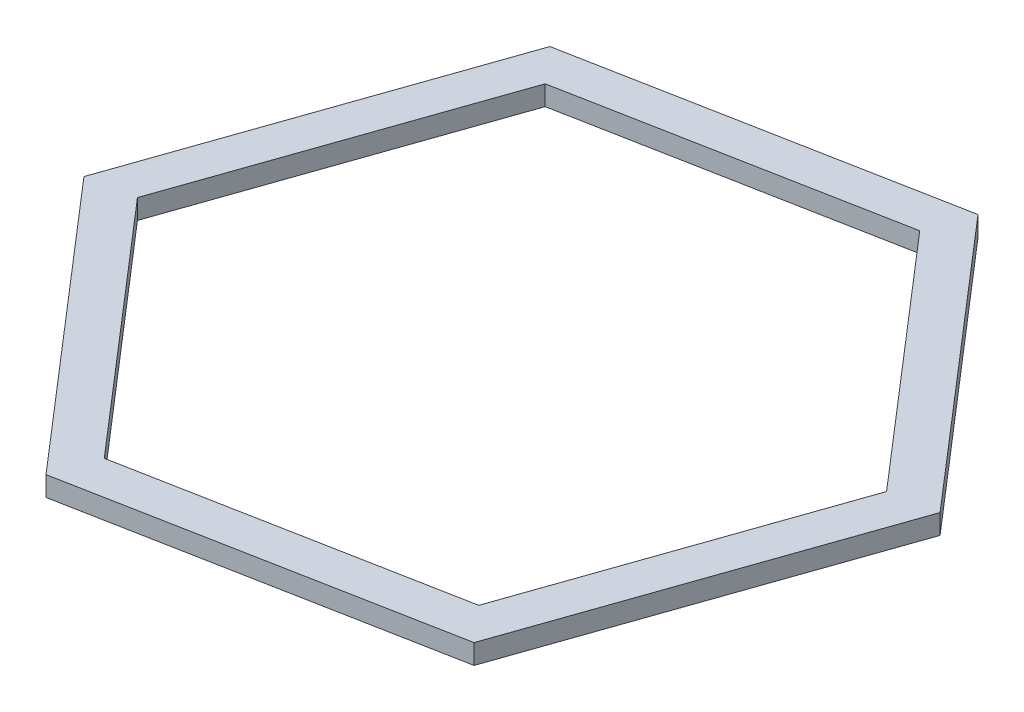
from build123d import *

# Parameters (mm, degrees)
EXTRUDE_THIN3_DEPTH = 10


with BuildPart() as part:
    # Sketch1 → Extrude-Thin3 (new body)
    with BuildSketch(Plane(origin=(0, 0, 0), x_dir=(1, 0, 0), z_dir=(0, 1, 0))):
        Polygon((120.714393603, -139.859206622), (181.47882269, 34.612128152), (60.764429086, 174.471334774), (-120.714393603, 139.859206622), (-181.47882269, -34.612128152), (-60.764429086, -174.471334774), align=None)
        Polygon((105.624924019, -122.376608388), (158.793713703, 30.285563279), (53.168789684, 152.662171668), (-105.624924019, 122.376608388), (-158.793713703, -30.285563279), (-53.168789684, -152.662171668), align=None, mode=Mode.SUBTRACT)
    extrude(amount=EXTRUDE_THIN3_DEPTH)


solid = part.part
